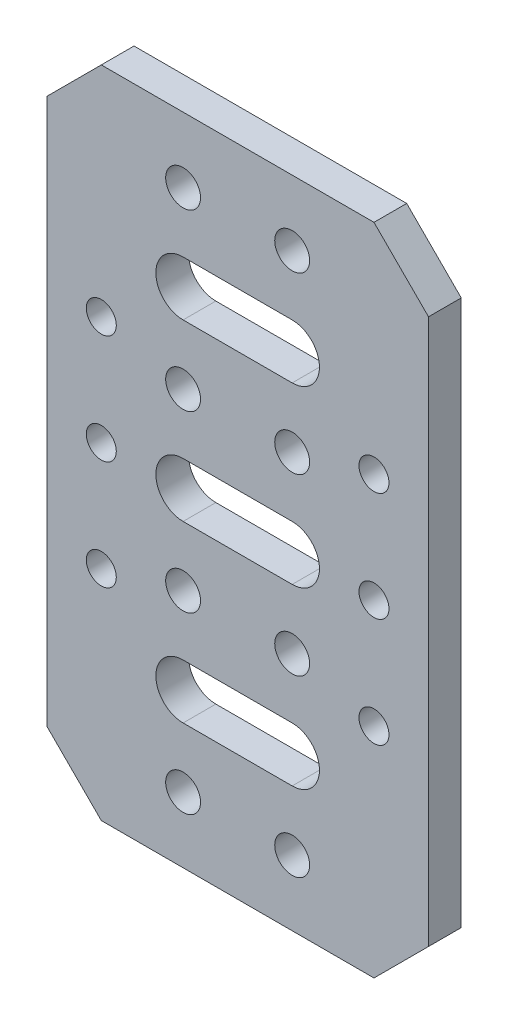
from build123d import *

# Parameters (mm, degrees)
SKETCH_1_W          = 35
SKETCH_1_H          = 60
SKETCH_1_R          = 1.6
EXTRUDE_1_DEPTH     = 3
CUT_EXTRUDE_1_REACH = 5
SKETCH_2_R          = 1.375
CHAMFER_1_SIZE      = 5
CUT_EXTRUDE_2_REACH = 5


with BuildPart() as part:
    # 草图1 → 凸台-拉伸1 (new body)
    with BuildSketch(Plane.XY):
        Rectangle(SKETCH_1_W, SKETCH_1_H)
        with Locations((-5, 8)):
            Circle(SKETCH_1_R, mode=Mode.SUBTRACT)
        with Locations((5, 8)):
            Circle(SKETCH_1_R, mode=Mode.SUBTRACT)
        with Locations((-5, 24)):
            Circle(SKETCH_1_R, mode=Mode.SUBTRACT)
        with Locations((5, 24)):
            Circle(SKETCH_1_R, mode=Mode.SUBTRACT)
        with Locations((-5, -8)):
            Circle(SKETCH_1_R, mode=Mode.SUBTRACT)
        with Locations((5, -8)):
            Circle(SKETCH_1_R, mode=Mode.SUBTRACT)
        with Locations((-5, -24)):
            Circle(SKETCH_1_R, mode=Mode.SUBTRACT)
        with Locations((5, -24)):
            Circle(SKETCH_1_R, mode=Mode.SUBTRACT)
    extrude(amount=EXTRUDE_1_DEPTH)

    # 草图2 → 切除-拉伸1 (cut, up to next)
    with BuildSketch(Plane.XY.offset(3), mode=Mode.PRIVATE) as cut_extrude_1_sk1:
        with Locations((12.5, 0)):
            Circle(SKETCH_2_R)
    cut_extrude_1_tool1 = extrude(cut_extrude_1_sk1.sketch, amount=-CUT_EXTRUDE_1_REACH, mode=Mode.PRIVATE) & part.part
    add(cut_extrude_1_tool1.solids().sort_by_distance((12.5, 0, 3))[0], mode=Mode.SUBTRACT)
    # 草图2 → 切除-拉伸1 (cut, up to next)
    with BuildSketch(Plane.XY.offset(3), mode=Mode.PRIVATE) as cut_extrude_1_sk2:
        with Locations((-12.5, 0)):
            Circle(SKETCH_2_R)
    cut_extrude_1_tool2 = extrude(cut_extrude_1_sk2.sketch, amount=-CUT_EXTRUDE_1_REACH, mode=Mode.PRIVATE) & part.part
    add(cut_extrude_1_tool2.solids().sort_by_distance((-12.5, 0, 3))[0], mode=Mode.SUBTRACT)
    # 草图2 → 切除-拉伸1 (cut, up to next)
    with BuildSketch(Plane.XY.offset(3), mode=Mode.PRIVATE) as cut_extrude_1_sk3:
        with Locations((-12.5, 10)):
            Circle(SKETCH_2_R)
    cut_extrude_1_tool3 = extrude(cut_extrude_1_sk3.sketch, amount=-CUT_EXTRUDE_1_REACH, mode=Mode.PRIVATE) & part.part
    add(cut_extrude_1_tool3.solids().sort_by_distance((-12.5, 10, 3))[0], mode=Mode.SUBTRACT)
    # 草图2 → 切除-拉伸1 (cut, up to next)
    with BuildSketch(Plane.XY.offset(3), mode=Mode.PRIVATE) as cut_extrude_1_sk4:
        with Locations((12.5, 10)):
            Circle(SKETCH_2_R)
    cut_extrude_1_tool4 = extrude(cut_extrude_1_sk4.sketch, amount=-CUT_EXTRUDE_1_REACH, mode=Mode.PRIVATE) & part.part
    add(cut_extrude_1_tool4.solids().sort_by_distance((12.5, 10, 3))[0], mode=Mode.SUBTRACT)
    # 草图2 → 切除-拉伸1 (cut, up to next)
    with BuildSketch(Plane.XY.offset(3), mode=Mode.PRIVATE) as cut_extrude_1_sk5:
        with Locations((-12.5, -10)):
            Circle(SKETCH_2_R)
    cut_extrude_1_tool5 = extrude(cut_extrude_1_sk5.sketch, amount=-CUT_EXTRUDE_1_REACH, mode=Mode.PRIVATE) & part.part
    add(cut_extrude_1_tool5.solids().sort_by_distance((-12.5, -10, 3))[0], mode=Mode.SUBTRACT)
    # 草图2 → 切除-拉伸1 (cut, up to next)
    with BuildSketch(Plane.XY.offset(3), mode=Mode.PRIVATE) as cut_extrude_1_sk6:
        with Locations((12.5, -10)):
            Circle(SKETCH_2_R)
    cut_extrude_1_tool6 = extrude(cut_extrude_1_sk6.sketch, amount=-CUT_EXTRUDE_1_REACH, mode=Mode.PRIVATE) & part.part
    add(cut_extrude_1_tool6.solids().sort_by_distance((12.5, -10, 3))[0], mode=Mode.SUBTRACT)

    # 倒角1
    chamfer_1_edges = [part.edges().sort_by_distance(p)[0] for p in [
        (17.5, -30, 1.5),
        (-17.5, -30, 1.5),
        (-17.5, 30, 1.5),
        (17.5, 30, 1.5),
    ]]
    chamfer(chamfer_1_edges, length=CHAMFER_1_SIZE)

    # 草图3 → 切除-拉伸2 (cut, up to next)
    with BuildSketch(Plane.XY.offset(3), mode=Mode.PRIVATE) as cut_extrude_2_sk1:
        with BuildLine():
            Line((-5, -2.5), (5, -2.5))
            ThreePointArc((5, -2.5), (7.5, 0), (5, 2.5))
            Line((5, 2.5), (-5, 2.5))
            ThreePointArc((-5, 2.5), (-7.5, 0), (-5, -2.5))
        make_face()
    cut_extrude_2_tool1 = extrude(cut_extrude_2_sk1.sketch, amount=-CUT_EXTRUDE_2_REACH, mode=Mode.PRIVATE) & part.part
    add(cut_extrude_2_tool1.solids().sort_by_distance((0, 0, 3))[0], mode=Mode.SUBTRACT)
    # 草图3 → 切除-拉伸2 (cut, up to next)
    with BuildSketch(Plane.XY.offset(3), mode=Mode.PRIVATE) as cut_extrude_2_sk2:
        with BuildLine():
            Line((-5, 13.5), (5, 13.5))
            ThreePointArc((5, 13.5), (7.5, 16), (5, 18.5))
            Line((5, 18.5), (-5, 18.5))
            ThreePointArc((-5, 18.5), (-7.5, 16), (-5, 13.5))
        make_face()
    cut_extrude_2_tool2 = extrude(cut_extrude_2_sk2.sketch, amount=-CUT_EXTRUDE_2_REACH, mode=Mode.PRIVATE) & part.part
    add(cut_extrude_2_tool2.solids().sort_by_distance((0, 16, 3))[0], mode=Mode.SUBTRACT)
    # 草图3 → 切除-拉伸2 (cut, up to next)
    with BuildSketch(Plane.XY.offset(3), mode=Mode.PRIVATE) as cut_extrude_2_sk3:
        with BuildLine():
            Line((-5, -18.5), (5, -18.5))
            ThreePointArc((5, -18.5), (7.5, -16), (5, -13.5))
            Line((5, -13.5), (-5, -13.5))
            ThreePointArc((-5, -13.5), (-7.5, -16), (-5, -18.5))
        make_face()
    cut_extrude_2_tool3 = extrude(cut_extrude_2_sk3.sketch, amount=-CUT_EXTRUDE_2_REACH, mode=Mode.PRIVATE) & part.part
    add(cut_extrude_2_tool3.solids().sort_by_distance((0, -16, 3))[0], mode=Mode.SUBTRACT)


solid = part.part
